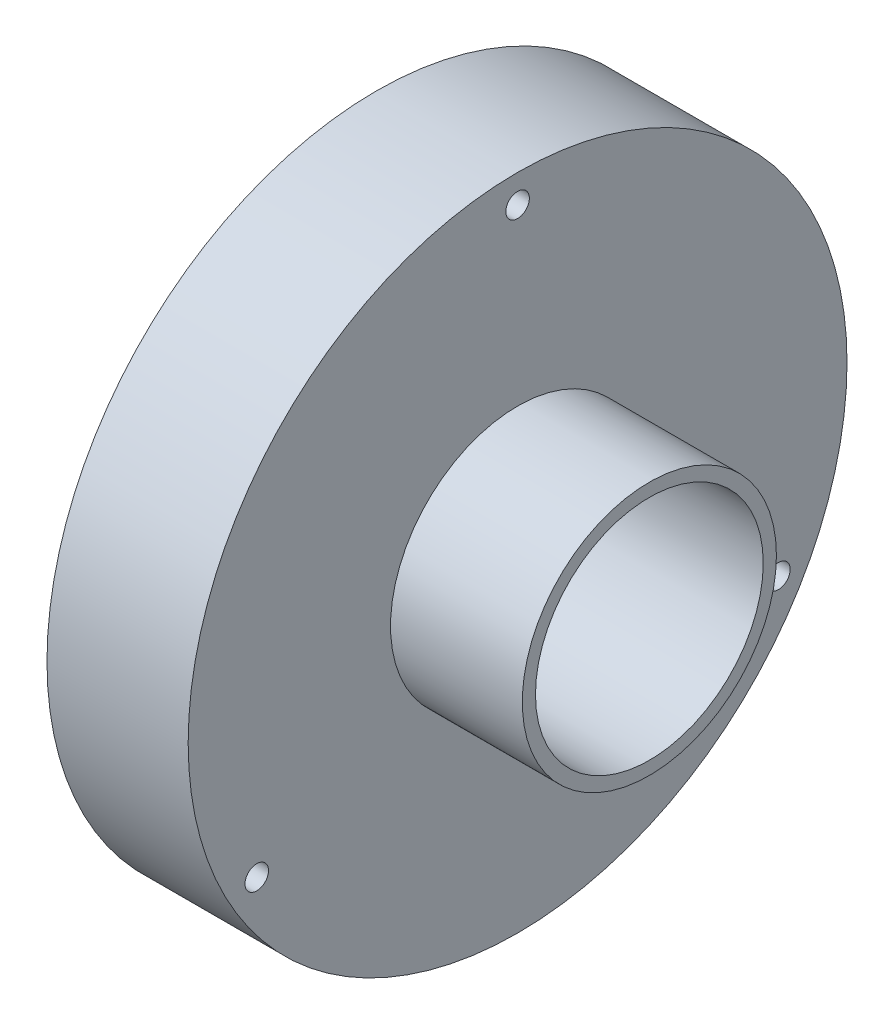
from build123d import *

# Parameters (mm, degrees)
BASPROSKE_W         = 5
BASPROSKE_H         = 4.25
TOOTHCUT_DEPTH      = 26.248762346
TEETHCUTS_COUNT     = 55
TEETHCUTS_ANGLE     = 353.454545455
BOSS_EXTRUDE1_START = 2.5
SKETCH1_R           = 17.5
SKETCH1_R_2         = 5.25
BOSS_EXTRUDE1_DEPTH = 2.5
SKETCH2_R           = 7.75
SKETCH2_R_2         = 5.25
BOSS_EXTRUDE2_DEPTH = 2.5
SKETCH3_R           = 6.05
CUT_EXTRUDE1_DEPTH  = 3.5
M1_6_TAPPED_HOLE1_D = 1.25
CIRPATTERN1_COUNT   = 3
SKETCH7_R           = 6.75
BOSS_EXTRUDE3_DEPTH = 7
SKETCH8_R           = 6.05
CUT_EXTRUDE2_DEPTH  = 7


with BuildPart() as part:
    # BasProSke → Base-Revolve (revolve)
    with BuildSketch(Plane(origin=(0, 0, 0), x_dir=(1, 0, 0), z_dir=(0, 1, 0))):
        with Locations((2.5, 15.375)):
            Rectangle(BASPROSKE_W, BASPROSKE_H)
    revolve(axis=Axis((-10, 0, 0), (1, 0, 0)))

    # TooCutSke → ToothCut (cut, through all)
    with BuildSketch(Plane(origin=(0, 0, 0), x_dir=(0, 0, -1), z_dir=(1, 0, 0))):
        with BuildLine():
            ThreePointArc((0.61765291, 13.210168434), (0.417066145, 13.802967889), (0.163405078, 14.375071297))
            ThreePointArc((0.163405078, 14.375071297), (0, 14.376), (-0.163405078, 14.375071297))
            ThreePointArc((-0.163405078, 14.375071297), (-0.417066145, 13.802967889), (-0.61765291, 13.210168434))
            ThreePointArc((-0.61765291, 13.210168434), (0, 13.2246), (0.61765291, 13.210168434))
        make_face()
    toothcut = extrude(amount=TOOTHCUT_DEPTH, mode=Mode.SUBTRACT)

    # TeethCuts: ToothCut ×55 about axis
    teethcuts_axis = Axis((-10, 0, 0), (1, 0, 0))
    for i in range(1, TEETHCUTS_COUNT):
        add(toothcut.rotate(teethcuts_axis, i * TEETHCUTS_ANGLE / (TEETHCUTS_COUNT - 1)), mode=Mode.SUBTRACT)

    # Sketch1 → Boss-Extrude1 (add)
    with BuildSketch(Plane(origin=(5, 0, 0), x_dir=(0, 0, -1), z_dir=(1, 0, 0)).offset(BOSS_EXTRUDE1_START)):
        Circle(SKETCH1_R)
        Circle(SKETCH1_R_2, mode=Mode.SUBTRACT)
    extrude(amount=-BOSS_EXTRUDE1_DEPTH)

    # Sketch2 → Boss-Extrude2 (add)
    with BuildSketch(Plane.ZY.offset(-5)):
        Circle(SKETCH2_R)
        Circle(SKETCH2_R_2, mode=Mode.SUBTRACT)
    extrude(amount=BOSS_EXTRUDE2_DEPTH)

    # Sketch3 → Cut-Extrude1 (cut)
    with BuildSketch(Plane(origin=(7.5, 0, 0), x_dir=(0, 0, -1), z_dir=(1, 0, 0))):
        Circle(SKETCH3_R)
    extrude(amount=-CUT_EXTRUDE1_DEPTH, mode=Mode.SUBTRACT)

    # M1.6 Tapped Hole1 (through all)
    with Locations(Plane(origin=(7.5, 0, 0), x_dir=(0, 0, -1), z_dir=(1, 0, 0))):
        with Locations((0, 16)):
            m1_6_tapped_hole1 = Hole(M1_6_TAPPED_HOLE1_D / 2)

    # CirPattern1: M1.6 Tapped Hole1 ×3 about axis
    cirpattern1_axis = Axis((7.5, 0, 0), (-1, 0, 0))
    for i in range(1, CIRPATTERN1_COUNT):
        add(m1_6_tapped_hole1.rotate(cirpattern1_axis, i * 360 / CIRPATTERN1_COUNT), mode=Mode.SUBTRACT)

    # Sketch7 → Boss-Extrude3 (add)
    with BuildSketch(Plane(origin=(7.5, 0, 0), x_dir=(0, 0, -1), z_dir=(1, 0, 0))):
        Circle(SKETCH7_R)
    extrude(amount=BOSS_EXTRUDE3_DEPTH)

    # Sketch8 → Cut-Extrude2 (cut)
    with BuildSketch(Plane(origin=(14.5, 0, 0), x_dir=(0, 0, -1), z_dir=(1, 0, 0))):
        Circle(SKETCH8_R)
    extrude(amount=-CUT_EXTRUDE2_DEPTH, mode=Mode.SUBTRACT)


solid = part.part
